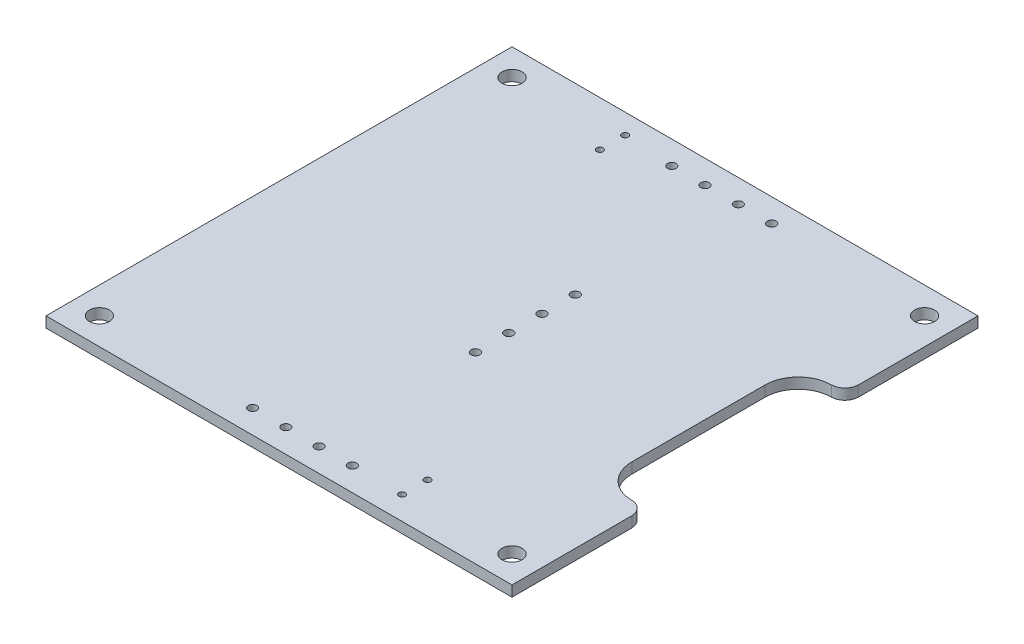
from build123d import *

# Parameters (mm, degrees)
SKETCH1_R           = 0.645583979
SKETCH1_R_2         = 0.656166882
SKETCH1_R_3         = 0.486835056
SKETCH1_R_4         = 1.5
BOSS_EXTRUDE1_DEPTH = 1.6


with BuildPart() as part:
    # Sketch1 → Boss-Extrude1 (new body)
    with BuildSketch(Plane(origin=(0, 0, 0), x_dir=(1, 0, 0), z_dir=(0, 1, 0))):
        with BuildLine():
            Line((35.009657829, 35.009663213), (-35.009668596, 35.009663213))
            Line((-35.009668596, 35.009663213), (-35.009668596, -35.009663213))
            Line((-35.009668596, -35.009663213), (35.009668596, -35.009663213))
            Line((35.009668596, -35.009663213), (35.009668596, -16.996819979))
            Line((35.009668596, -16.996819979), (34.988502791, -16.996830745))
            add(Edge.make_bspline(
                [(34.988502791, -16.996830745), (34.988502791, -15.896155035), (34.078330096, -15.007158911), (32.998830957, -15.007158912)],
                knots=[6, 6, 6, 6, 7, 7, 7, 7], degree=3))
            Line((32.998830957, -15.007158912), (32.977665152, -14.985993106))
            add(Edge.make_bspline(
                [(32.977665152, -14.985993106), (30.226002792, -14.985993106), (28.003507099, -12.742331608), (28.003507099, -9.990669248)],
                knots=[8, 8, 8, 8, 9, 9, 9, 9], degree=3))
            Line((28.003507099, -9.990669248), (28.003507099, 9.990669248))
            Line((28.003507099, 9.990669248), (28.003507099, 10.011835053))
            add(Edge.make_bspline(
                [(28.003507099, 10.011835053), (28.003507099, 12.784663218), (30.226002792, 15.007158911), (32.977675917, 15.007158911)],
                knots=[11, 11, 11, 11, 12, 12, 12, 12], degree=3))
            Line((32.977675917, 15.007158911), (32.99883634, 15.028319334))
            add(Edge.make_bspline(
                [(32.99883634, 15.028319334), (34.078335478, 15.028322254), (34.988494945, 15.938497412), (34.988492025, 17.017996551)],
                knots=[13, 13, 13, 13, 14, 14, 14, 14], degree=3))
            Line((34.988492025, 17.017996551), (35.00965783, 16.996830745))
            add(Edge.make_bspline(
                [(35.00965783, 16.996830745), (35.009657829, 35.009673979), (35.009657829, 35.009663213)],
                knots=[0, 0, 0, 1, 1, 1], degree=2))
        make_face()
        with Locations((-7.503590222, 31.517165368)):
            Circle(SKETCH1_R, mode=Mode.SUBTRACT)
        with Locations((-2.508255598, 31.517165368)):
            Circle(SKETCH1_R, mode=Mode.SUBTRACT)
        with Locations((2.487079026, 31.517165369)):
            Circle(SKETCH1_R, mode=Mode.SUBTRACT)
        with Locations((7.492996552, 31.517165369)):
            Circle(SKETCH1_R_2, mode=Mode.SUBTRACT)
        with Locations((-15.007175061, 28.215170536)):
            Circle(SKETCH1_R_3, mode=Mode.SUBTRACT)
        with Locations((-15.007175061, 32.004000424)):
            Circle(SKETCH1_R_3, mode=Mode.SUBTRACT)
        with Locations((1.989661068, 7.51416236)):
            Circle(SKETCH1_R_2, mode=Mode.SUBTRACT)
        with Locations((1.989661069, 2.518838502)):
            Circle(SKETCH1_R_2, mode=Mode.SUBTRACT)
        with Locations((1.989661069, -2.476496122)):
            Circle(SKETCH1_R_2, mode=Mode.SUBTRACT)
        with Locations((1.989661069, -7.492996551)):
            Circle(SKETCH1_R_2, mode=Mode.SUBTRACT)
        with Locations((-7.503590219, -31.474833755)):
            Circle(SKETCH1_R, mode=Mode.SUBTRACT)
        with Locations((-2.508255595, -31.474833755)):
            Circle(SKETCH1_R, mode=Mode.SUBTRACT)
        with Locations((2.487079029, -31.474833754)):
            Circle(SKETCH1_R, mode=Mode.SUBTRACT)
        with Locations((7.492996555, -31.474833754)):
            Circle(SKETCH1_R_2, mode=Mode.SUBTRACT)
        with Locations((-31.009175272, 31.009164506)):
            Circle(SKETCH1_R_4, mode=Mode.SUBTRACT)
        with Locations((30.9879987, 31.009164509)):
            Circle(SKETCH1_R_4, mode=Mode.SUBTRACT)
        with Locations((-31.009175269, -30.9879987)):
            Circle(SKETCH1_R_4, mode=Mode.SUBTRACT)
        with Locations((30.987998703, -30.987998698)):
            Circle(SKETCH1_R_4, mode=Mode.SUBTRACT)
        with Locations((14.985998491, -27.686003867)):
            Circle(SKETCH1_R_3, mode=Mode.SUBTRACT)
        with Locations((14.985998491, -31.495999559)):
            Circle(SKETCH1_R_3, mode=Mode.SUBTRACT)
    extrude(amount=BOSS_EXTRUDE1_DEPTH)


solid = part.part
